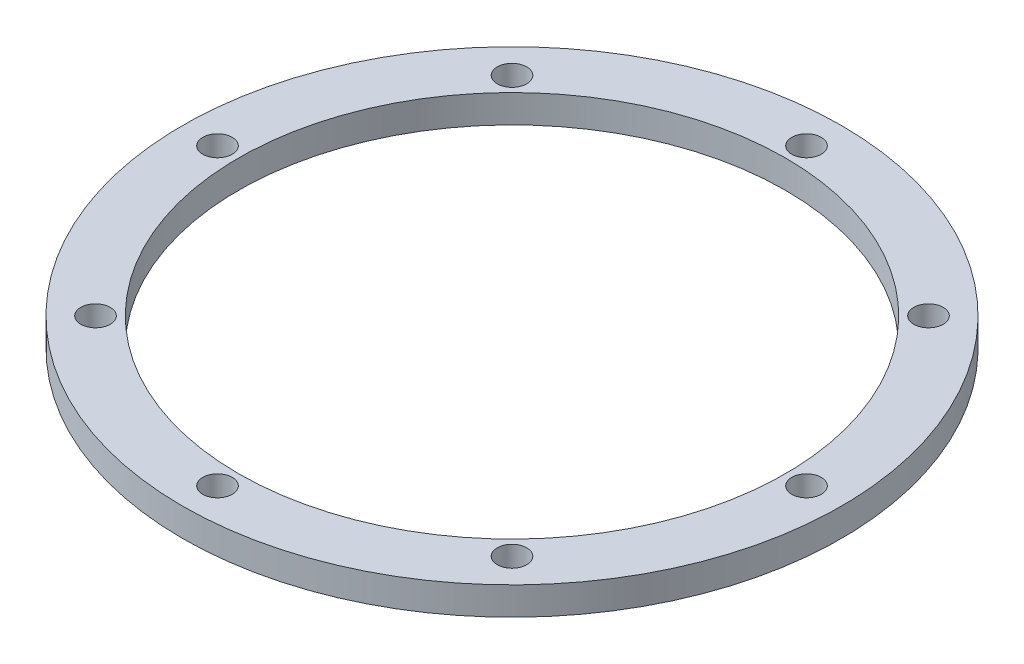
from build123d import *

# Parameters (mm, degrees)
SKETCH_1_W          = 8
SKETCH_1_H          = 4
SKETCH_2_R          = 2.1
CUT_EXTRUDE_1_DEPTH = 10


with BuildPart() as part:
    # 草图1 → 旋转1 (revolve)
    with BuildSketch(Plane.XY):
        with Locations((-43, 2)):
            Rectangle(SKETCH_1_W, SKETCH_1_H)
    revolve(axis=Axis((0, 0, 0), (0, 1, 0)))

    # 草图2 → 切除-拉伸1 (cut)
    with BuildSketch(Plane.XZ):
        with Locations((0, 42)):
            Circle(SKETCH_2_R)
        with Locations((29.69848481, 29.69848481)):
            Circle(SKETCH_2_R)
        with Locations((42, 0)):
            Circle(SKETCH_2_R)
        with Locations((29.69848481, -29.69848481)):
            Circle(SKETCH_2_R)
        with Locations((0, -42)):
            Circle(SKETCH_2_R)
        with Locations((-29.69848481, -29.69848481)):
            Circle(SKETCH_2_R)
        with Locations((-42, 0)):
            Circle(SKETCH_2_R)
        with Locations((-29.69848481, 29.69848481)):
            Circle(SKETCH_2_R)
    extrude(amount=-CUT_EXTRUDE_1_DEPTH, mode=Mode.SUBTRACT)


solid = part.part
